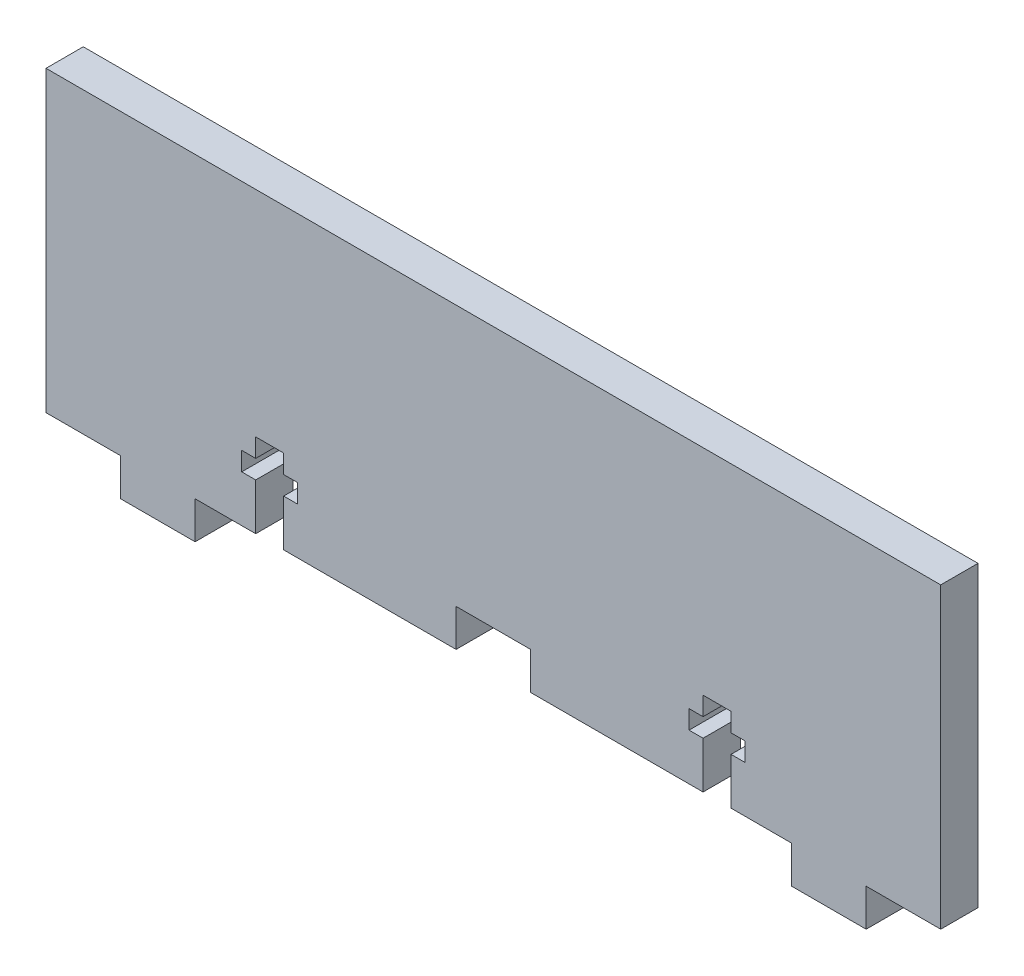
from build123d import *

# Parameters (mm, degrees)
BOSS_EXTRUDE1_DEPTH = 6.35
SKETCH2_W           = 12.7
SKETCH2_H           = 6.35
CUT_EXTRUDE1_DEPTH  = 6.35


with BuildPart() as part:
    # Sketch1 → Boss-Extrude1 (new body)
    with BuildSketch(Plane.XY):
        Polygon((139.7, 6.35), (152.4, 6.35), (152.4, 57.15), (0, 57.15), (0, 6.35), (12.7, 6.35), (12.7, 0), (25.4, 0), (25.4, 6.35), (127, 6.35), (127, 0), (139.7, 0), align=None)
    extrude(amount=BOSS_EXTRUDE1_DEPTH)

    # Sketch2 → Cut-Extrude1 (cut)
    with BuildSketch(Plane.XY.offset(6.35)):
        Polygon((111.91875, 6.35), (111.91875, 14.2875), (109.5375, 14.2875), (109.5375, 17.4625), (111.91875, 17.4625), (111.91875, 20.6375), (116.68125, 20.6375), (116.68125, 17.4625), (119.0625, 17.4625), (119.0625, 14.2875), (116.68125, 14.2875), (116.68125, 6.35), align=None)
        Polygon((42.8625, 17.4625), (42.8625, 14.2875), (40.48125, 14.2875), (40.48125, 6.35), (35.71875, 6.35), (35.71875, 14.2875), (33.3375, 14.2875), (33.3375, 17.4625), (35.71875, 17.4625), (35.71875, 20.6375), (40.48125, 20.6375), (40.48125, 17.4625), align=None)
        with Locations((76.2, 9.525)):
            Rectangle(SKETCH2_W, SKETCH2_H)
    extrude(amount=-CUT_EXTRUDE1_DEPTH, mode=Mode.SUBTRACT)


solid = part.part
